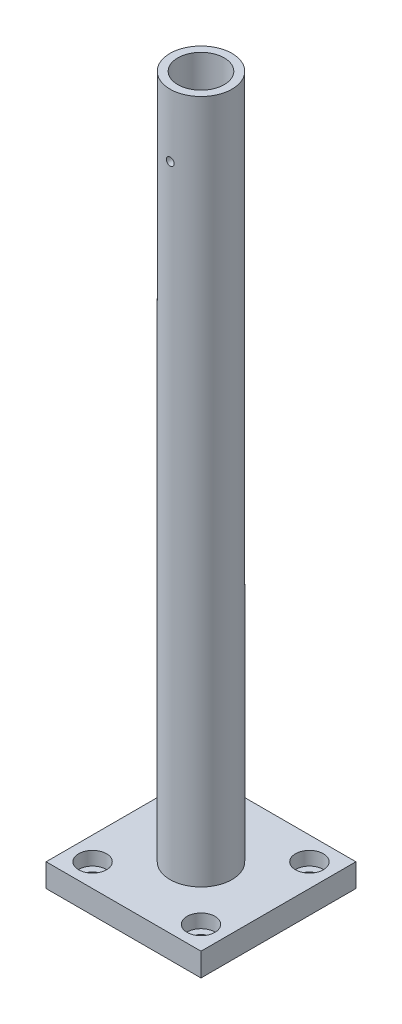
from build123d import *

# Parameters (mm, degrees)
SKETCH4_W           = 100
SKETCH4_H           = 100
BOSS_EXTRUDE4_DEPTH = 15
SKETCH5_R           = 20
SKETCH5_R_2         = 15
BOSS_EXTRUDE5_DEPTH = 442
SKETCH8_R           = 2.5
CUT_EXTRUDE2_DEPTH  = 334
SKETCH9_R           = 4.5
CUT_EXTRUDE3_DEPTH  = 334
SKETCH10_R          = 9
CUT_EXTRUDE4_DEPTH  = 8.8


with BuildPart() as part:
    # Sketch4 → Boss-Extrude4 (new body)
    with BuildSketch(Plane(origin=(0, 0, 0), x_dir=(1, 0, 0), z_dir=(0, 1, 0))):
        with Locations((50, 50)):
            Rectangle(SKETCH4_W, SKETCH4_H)
    extrude(amount=BOSS_EXTRUDE4_DEPTH)

    # Sketch5 → Boss-Extrude5 (add)
    with BuildSketch(Plane(origin=(0, 15, 0), x_dir=(1, 0, 0), z_dir=(0, 1, 0))):
        with Locations((50, 50)):
            Circle(SKETCH5_R)
        with Locations((50, 50)):
            Circle(SKETCH5_R_2, mode=Mode.SUBTRACT)
    extrude(amount=BOSS_EXTRUDE5_DEPTH)

    # Sketch8 → Cut-Extrude2 (cut)
    with BuildSketch(Plane.XY):
        with Locations((50, 416.5)):
            Circle(SKETCH8_R)
    extrude(amount=-CUT_EXTRUDE2_DEPTH, mode=Mode.SUBTRACT)

    # Sketch9 → Cut-Extrude3 (cut)
    with BuildSketch(Plane(origin=(0, 15, 0), x_dir=(1, 0, 0), z_dir=(0, 1, 0))):
        with Locations((15, 85)):
            Circle(SKETCH9_R)
        with Locations((85, 85)):
            Circle(SKETCH9_R)
        with Locations((85, 15)):
            Circle(SKETCH9_R)
        with Locations((15, 15)):
            Circle(SKETCH9_R)
    extrude(amount=-CUT_EXTRUDE3_DEPTH, mode=Mode.SUBTRACT)

    # Sketch10 → Cut-Extrude4 (cut)
    with BuildSketch(Plane(origin=(0, 15, 0), x_dir=(1, 0, 0), z_dir=(0, 1, 0))):
        with Locations((15, 85)):
            Circle(SKETCH10_R)
        with Locations((85, 85)):
            Circle(SKETCH10_R)
        with Locations((85, 15)):
            Circle(SKETCH10_R)
        with Locations((15, 15)):
            Circle(SKETCH10_R)
    extrude(amount=-CUT_EXTRUDE4_DEPTH, mode=Mode.SUBTRACT)


solid = part.part
